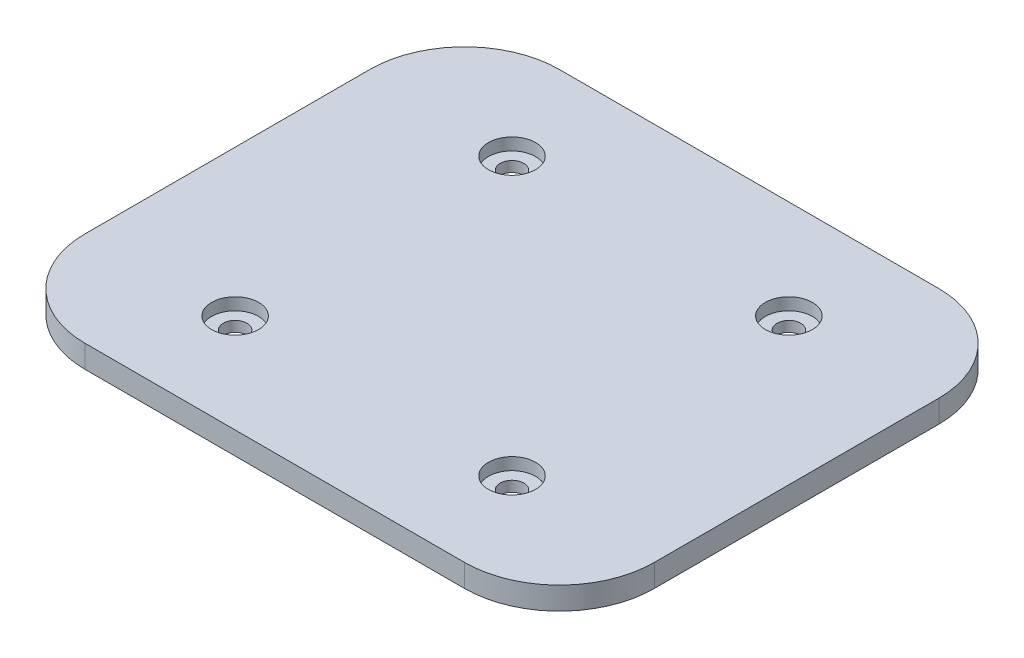
from build123d import *

# Parameters (mm, degrees)
BOSS_EXTRUDE1_DEPTH                             = 4.7625
CBORE_FOR_10_BUTTON_HEAD_CAP_SCREW1_D           = 4.9784
CBORE_FOR_10_BUTTON_HEAD_CAP_SCREW1_CBORE_D     = 9.92124
CBORE_FOR_10_BUTTON_HEAD_CAP_SCREW1_CBORE_DEPTH = 2.5654


with BuildPart() as part:
    # Sketch1 → Boss-Extrude1 (new body)
    with BuildSketch(Plane(origin=(0, 0, 0), x_dir=(1, 0, 0), z_dir=(0, 1, 0))):
        with BuildLine():
            Line((40, -50), (-40, -50))
            ThreePointArc((-40, -50), (-54.142135624, -44.142135624), (-60, -30))
            Line((-60, -30), (-60, 30))
            ThreePointArc((-60, 30), (-54.142135624, 44.142135624), (-40, 50))
            Line((-40, 50), (40, 50))
            ThreePointArc((40, 50), (54.142135624, 44.142135624), (60, 30))
            Line((60, 30), (60, -30))
            ThreePointArc((60, -30), (54.142135624, -44.142135624), (40, -50))
        make_face()
    extrude(amount=BOSS_EXTRUDE1_DEPTH)

    # CBORE for #10 Button Head Cap Screw1 (through all)
    with Locations(Plane(origin=(0, 4.7625, 0), x_dir=(1, 0, 0), z_dir=(0, 1, 0))):
        with Locations((29.185832393, 29.185832393), (29.185832393, -29.185832393), (-29.185832393, -29.185832393), (-29.185832393, 29.185832393)):
            CounterBoreHole(CBORE_FOR_10_BUTTON_HEAD_CAP_SCREW1_D / 2, CBORE_FOR_10_BUTTON_HEAD_CAP_SCREW1_CBORE_D / 2, CBORE_FOR_10_BUTTON_HEAD_CAP_SCREW1_CBORE_DEPTH)


solid = part.part
